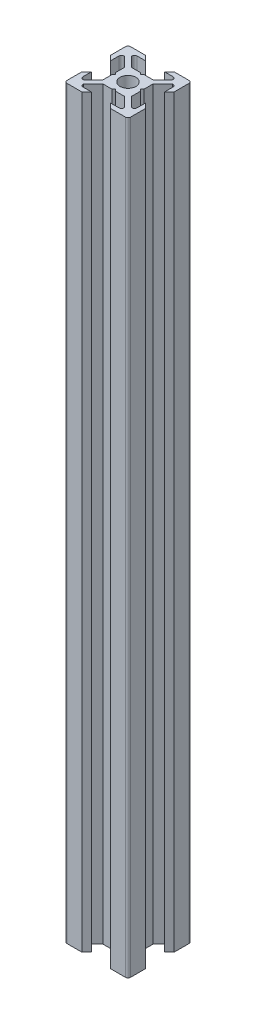
from build123d import *

# Parameters (mm, degrees)
ESQUISSE1_R      = 2.5
EXTRUSION1_DEPTH = 234.5
CONG_1_R         = 0.75


with BuildPart() as part:
    # Esquisse1 → Extrusion1 (new body)
    with BuildSketch(Plane(origin=(0, 0, 0), x_dir=(1, 0, 0), z_dir=(0, 1, 0))):
        Polygon((0, 4), (-0.5, 4.5), (-3.439339828, 4.5), (-6.439339828, 7.5), (-6.439339828, 8.5), (-3, 8.5), (-4.5, 10), (-10, 10), (-10, 4.5), (-8.5, 3), (-8.5, 6.439339828), (-7.5, 6.439339828), (-4.5, 3.439339828), (-4.5, 0.5), (-4, 0), (-4.5, -0.5), (-4.5, -3.439339828), (-7.5, -6.439339828), (-8.5, -6.439339828), (-8.5, -3), (-10, -4.5), (-10, -10), (-4.5, -10), (-3, -8.5), (-6.439339828, -8.5), (-6.439339828, -7.5), (-3.439339828, -4.5), (-0.5, -4.5), (0, -4), (0.5, -4.5), (3.439339828, -4.5), (6.439339828, -7.5), (6.439339828, -8.5), (3, -8.5), (4.5, -10), (10, -10), (10, -4.5), (8.5, -3), (8.5, -6.439339828), (7.5, -6.439339828), (4.5, -3.439339828), (4.5, -0.5), (4, 0), (4.5, 0.5), (4.5, 3.439339828), (7.5, 6.439339828), (8.5, 6.439339828), (8.5, 3), (10, 4.5), (10, 10), (4.5, 10), (3, 8.5), (6.439339828, 8.5), (6.439339828, 7.5), (3.439339828, 4.5), (0.5, 4.5), align=None)
        Circle(ESQUISSE1_R, mode=Mode.SUBTRACT)
    extrude(amount=EXTRUSION1_DEPTH)

    # Congé1
    cong_1_edges = [part.edges().sort_by_distance(p)[0] for p in [
        (6.439339828, 117.25, -8.5),
        (10, 117.25, -10),
        (8.5, 117.25, -6.439339828),
        (8.5, 117.25, 6.439339828),
        (10, 117.25, 10),
        (6.439339828, 117.25, 8.5),
        (-6.439339828, 117.25, 8.5),
        (-10, 117.25, 10),
        (-8.5, 117.25, 6.439339828),
        (-8.5, 117.25, -6.439339828),
        (-10, 117.25, -10),
        (-6.439339828, 117.25, -8.5),
    ]]
    fillet(cong_1_edges, radius=CONG_1_R)


solid = part.part
